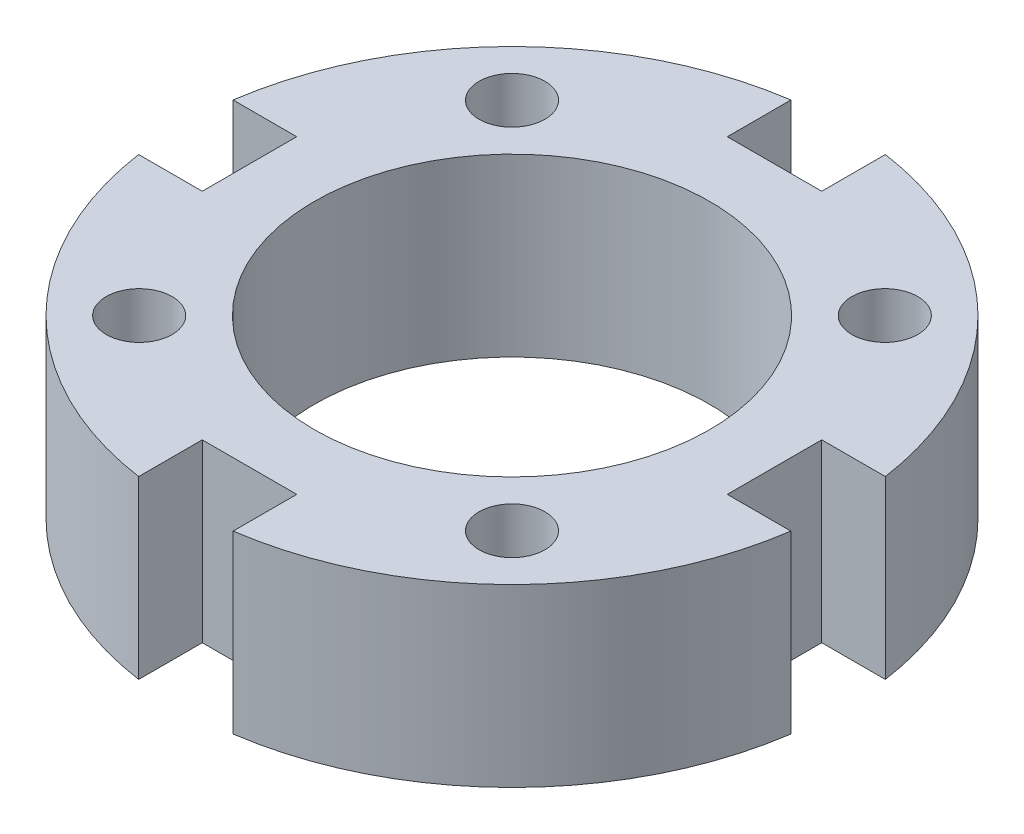
from build123d import *

# Parameters (mm, degrees)
SKETCH1_R           = 7.5
SKETCH1_R_2         = 4.5
BOSS_EXTRUDE1_DEPTH = 4
SKETCH3_W           = 1.525
SKETCH3_H           = 4
CUT_EXTRUDE1_DEPTH  = 1.075
CIRPATTERN1_COUNT   = 4
SKETCH6_R           = 0.75
CUT_EXTRUDE3_DEPTH  = 5
CIRPATTERN3_COUNT   = 4


with BuildPart() as part:
    # Sketch1 → Boss-Extrude1 (new body)
    with BuildSketch(Plane(origin=(0, 0, 0), x_dir=(1, 0, 0), z_dir=(0, 1, 0))):
        Circle(SKETCH1_R)
        Circle(SKETCH1_R_2, mode=Mode.SUBTRACT)
    extrude(amount=BOSS_EXTRUDE1_DEPTH)

    # Sketch3 → Cut-Extrude1 (cut, symmetric)
    with BuildSketch(Plane(origin=(0, 0, 0), x_dir=(0, 0, -1), z_dir=(1, 0, 0))):
        with Locations((-6.7375, 2)):
            Rectangle(SKETCH3_W, SKETCH3_H)
    cut_extrude1 = extrude(amount=CUT_EXTRUDE1_DEPTH, both=True, mode=Mode.SUBTRACT)

    # CirPattern1: Cut-Extrude1 ×4 about axis
    cirpattern1_axis = Axis((0, 0, 0), (0, 1, 0))
    for i in range(1, CIRPATTERN1_COUNT):
        add(cut_extrude1.rotate(cirpattern1_axis, i * 360 / CIRPATTERN1_COUNT), mode=Mode.SUBTRACT)

    # Sketch6 → Cut-Extrude3 (cut, through all)
    with BuildSketch(Plane.XZ):
        with Locations((4.242640687, 4.242640687)):
            Circle(SKETCH6_R)
    cut_extrude3 = extrude(amount=-CUT_EXTRUDE3_DEPTH, mode=Mode.SUBTRACT)

    # CirPattern3: Cut-Extrude3 ×4 about axis
    cirpattern3_axis = Axis((0, 0, 0), (0, 1, 0))
    for i in range(1, CIRPATTERN3_COUNT):
        add(cut_extrude3.rotate(cirpattern3_axis, i * 360 / CIRPATTERN3_COUNT), mode=Mode.SUBTRACT)


solid = part.part
